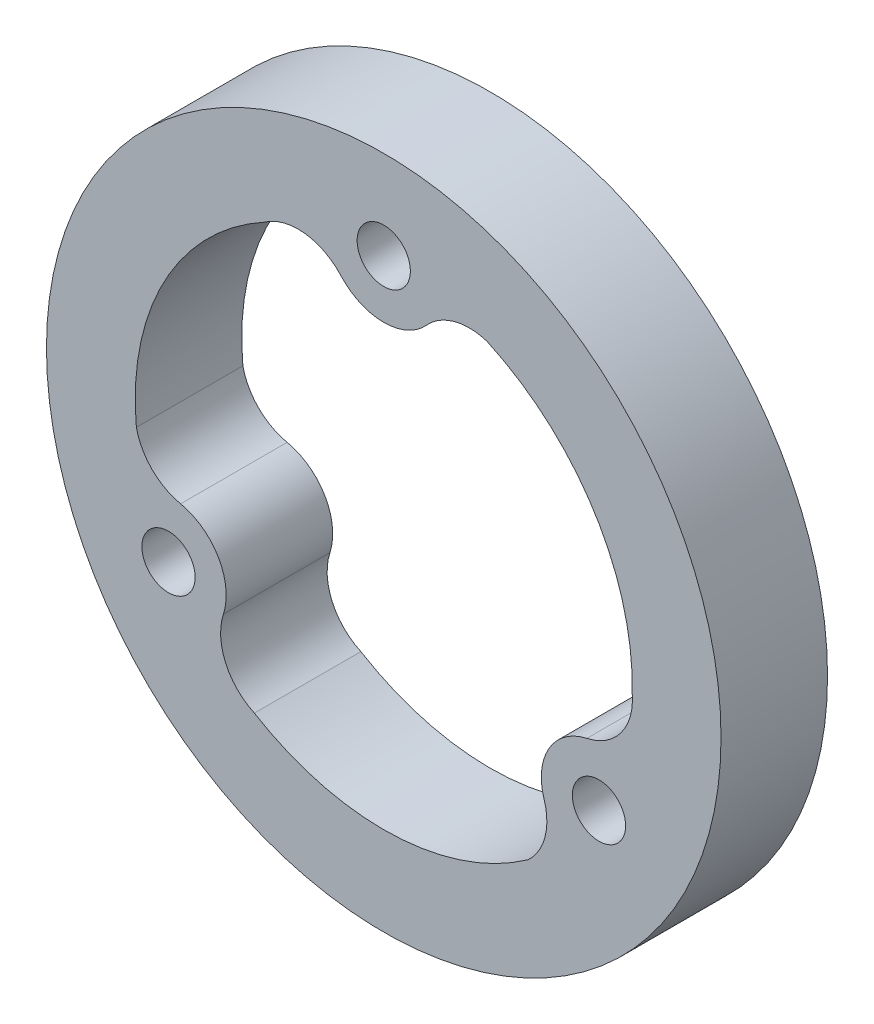
from build123d import *

# Parameters (mm, degrees)
ESQUISSE1_R        = 19
ESQUISSE1_R_2      = 1.5
BOSS_EXTRU_2_DEPTH = 6


with BuildPart() as part:
    # Esquisse1 → Boss.-Extru.2 (new body)
    with BuildSketch(Plane.XY):
        Circle(ESQUISSE1_R)
        with Locations((0, 14)):
            Circle(ESQUISSE1_R_2, mode=Mode.SUBTRACT)
        with Locations((12.124355653, -7)):
            Circle(ESQUISSE1_R_2, mode=Mode.SUBTRACT)
        with Locations((-12.124355653, -7)):
            Circle(ESQUISSE1_R_2, mode=Mode.SUBTRACT)
        with BuildLine():
            ThreePointArc((-2.411034891, 11.820685714), (0, 10.75), (2.411034891, 11.820685714))
            ThreePointArc((2.411034891, 11.820685714), (3.975330286, 12.779130538), (5.80943088, 12.737759334))
            ThreePointArc((5.80943088, 12.737759334), (11.865562564, 7.430237213), (13.995977593, -0.335575935))
            ThreePointArc((13.995977593, -0.335575935), (13.382779595, -2.564868949), (11.442531564, -3.822325392))
            ThreePointArc((11.442531564, -3.822325392), (9.309773091, -5.375), (9.031496673, -7.998360322))
            ThreePointArc((9.031496673, -7.998360322), (9.079386541, -9.832302285), (8.126507731, -11.399994391))
            ThreePointArc((8.126507731, -11.399994391), (0.5019929, -13.990997217), (-7.288606081, -11.953084179))
            ThreePointArc((-7.288606081, -11.953084179), (-8.912631465, -10.307392628), (-9.031496673, -7.998360322))
            ThreePointArc((-9.031496673, -7.998360322), (-9.309773091, -5.375), (-11.442531564, -3.822325392))
            ThreePointArc((-11.442531564, -3.822325392), (-13.054716827, -2.946828253), (-13.935938611, -1.337764944))
            ThreePointArc((-13.935938611, -1.337764944), (-12.367555464, 6.560760004), (-6.707371512, 12.288660114))
            ThreePointArc((-6.707371512, 12.288660114), (-4.47014813, 12.872261577), (-2.411034891, 11.820685714))
        make_face(mode=Mode.SUBTRACT)
    extrude(amount=BOSS_EXTRU_2_DEPTH)


solid = part.part
